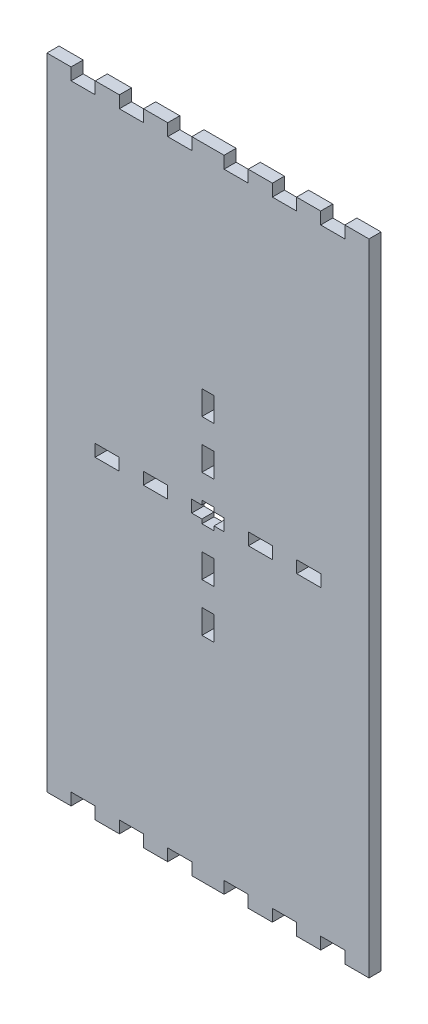
from build123d import *

# Parameters (mm, degrees)
SKETCH1_W           = 6
SKETCH1_H           = 3
SKETCH1_W_2         = 3
SKETCH1_H_2         = 6
BOSS_EXTRUDE1_DEPTH = 3


with BuildPart() as part:
    # Sketch1 → Boss-Extrude1 (new body)
    with BuildSketch(Plane.XY):
        Polygon((-34, 76.5), (-28, 76.5), (-28, 79.5), (-22, 79.5), (-22, 76.5), (-16, 76.5), (-16, 79.5), (-10, 79.5), (-10, 76.5), (-4, 76.5), (-4, 79.5), (0, 79.5), (4, 79.5), (4, 76.5), (10, 76.5), (10, 79.5), (16, 79.5), (16, 76.5), (22, 76.5), (22, 79.5), (28, 79.5), (28, 76.5), (34, 76.5), (34, 79.5), (40, 79.5), (40, 76.5), (40, -76.5), (40, -79.5), (34, -79.5), (34, -76.5), (28, -76.5), (28, -79.5), (22, -79.5), (22, -76.5), (16, -76.5), (16, -79.5), (10, -79.5), (10, -76.5), (4, -76.5), (4, -79.5), (0, -79.5), (-4, -79.5), (-4, -76.5), (-10, -76.5), (-10, -79.5), (-16, -79.5), (-16, -76.5), (-22, -76.5), (-22, -79.5), (-28, -79.5), (-28, -76.5), (-34, -76.5), (-34, -79.5), (-40, -79.5), (-40, -76.5), (-40, 76.5), (-40, 79.5), (-34, 79.5), align=None)
        Polygon((-1.503424482, 2.54), (1.503424482, 2.54), (1.503424482, 1.5), (4.04, 1.5), (4.04, -1.5), (1.503424482, -1.5), (1.503424482, -2.54), (-1.503424482, -2.54), (-1.503424482, -1.5), (-4.04, -1.5), (-4.04, 1.5), (-1.503424482, 1.5), align=None, mode=Mode.SUBTRACT)
        with Locations((25.04, 0)):
            Rectangle(SKETCH1_W, SKETCH1_H, mode=Mode.SUBTRACT)
        with Locations((-13.04, 0)):
            Rectangle(SKETCH1_W, SKETCH1_H, mode=Mode.SUBTRACT)
        with Locations((-25.04, 0)):
            Rectangle(SKETCH1_W, SKETCH1_H, mode=Mode.SUBTRACT)
        with Locations((13.04, 0)):
            Rectangle(SKETCH1_W, SKETCH1_H, mode=Mode.SUBTRACT)
        with Locations((0, -23.54)):
            Rectangle(SKETCH1_W_2, SKETCH1_H_2, mode=Mode.SUBTRACT)
        with Locations((0, 11.54)):
            Rectangle(SKETCH1_W_2, SKETCH1_H_2, mode=Mode.SUBTRACT)
        with Locations((0, 23.54)):
            Rectangle(SKETCH1_W_2, SKETCH1_H_2, mode=Mode.SUBTRACT)
        with Locations((0, -11.54)):
            Rectangle(SKETCH1_W_2, SKETCH1_H_2, mode=Mode.SUBTRACT)
    extrude(amount=BOSS_EXTRUDE1_DEPTH)


solid = part.part
